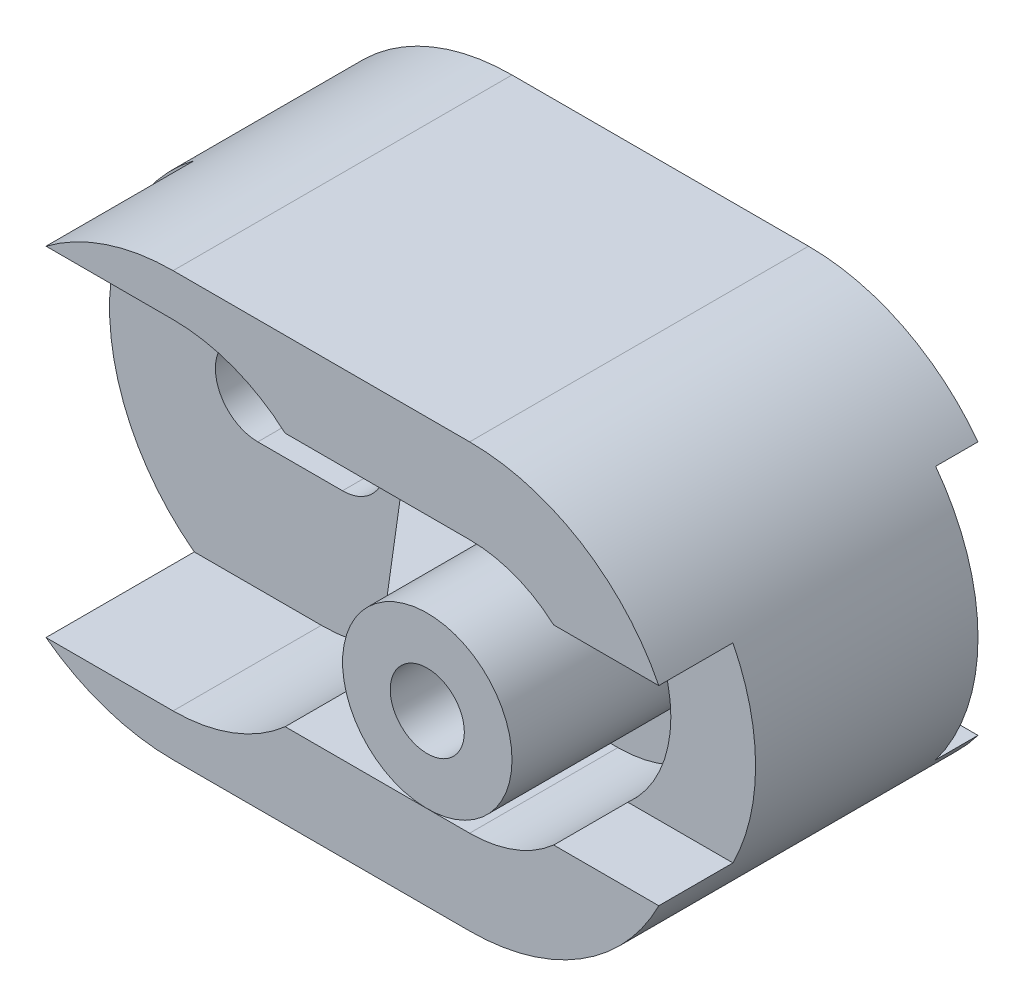
from build123d import *

# Parameters (mm, degrees)
BOSS_EXTRUDE1_DEPTH = 8
SKETCH2_W           = 1
SKETCH2_H           = 6
CUT_EXTRUDE1_DEPTH  = 9
CUT_EXTRUDE2_DEPTH  = 1
SKETCH4_R           = 2
CUT_EXTRUDE3_DEPTH  = 3.5
BOSS_EXTRUDE3_DEPTH = 0.5
CUT_EXTRUDE4_DEPTH  = 6.025665282
CUT_EXTRUDE5_DEPTH  = 1.75
SKETCH8_R           = 2
BOSS_EXTRUDE4_DEPTH = 1


with BuildPart() as part:
    # Sketch1 → Boss-Extrude1 (new body)
    with BuildSketch(Plane.XY):
        with BuildLine():
            Line((-3.5, 5), (3.5, 5))
            ThreePointArc((3.5, 5), (8.5, 0), (3.5, -5))
            Line((3.5, -5), (-3.5, -5))
            ThreePointArc((-3.5, -5), (-8.5, 0), (-3.5, 5))
        make_face()
    extrude(amount=BOSS_EXTRUDE1_DEPTH)

    # Sketch2 → Cut-Extrude1 (cut, symmetric)
    with BuildSketch(Plane(origin=(0, 0, 0), x_dir=(0, 0, -1), z_dir=(1, 0, 0))):
        with Locations((-0.5, 0)):
            Rectangle(SKETCH2_W, SKETCH2_H)
    extrude(amount=CUT_EXTRUDE1_DEPTH, both=True, mode=Mode.SUBTRACT)

    # Sketch3 → Cut-Extrude2 (cut)
    with BuildSketch(Plane(origin=(0, 0, 1), x_dir=(-1, 0, 0), z_dir=(0, 0, -1))):
        with BuildLine():
            Line((3.000904035, 2), (8.5, 2))
            ThreePointArc((8.5, 2), (10.5, 0), (8.5, -2))
            Line((8.5, -2), (3.000904035, -2))
            ThreePointArc((3.000904035, -2), (1.000904035, 0), (3.000904035, 2))
        make_face()
    extrude(amount=-CUT_EXTRUDE2_DEPTH, mode=Mode.SUBTRACT)

    # Sketch4 → Cut-Extrude3 (cut)
    with BuildSketch(Plane.XY.offset(8)):
        with BuildLine():
            Line((-9.161583496, 4), (-3.5, 4))
            ThreePointArc((-3.5, 4), (0.5, 0), (-3.5, -4))
            Line((-3.5, -4), (-9.161583496, -4))
            ThreePointArc((-9.161583496, -4), (-13.161583496, 0), (-9.161583496, 4))
        make_face()
        with BuildLine():
            Line((-3.5, 3), (3.5, 3))
            ThreePointArc((3.5, 3), (6.5, 0), (3.5, -3))
            Line((3.5, -3), (-3.5, -3))
            ThreePointArc((-3.5, -3), (-6.5, 0), (-3.5, 3))
        make_face()
        with Locations((3.5, 0)):
            Circle(SKETCH4_R, mode=Mode.SUBTRACT)
    extrude(amount=-CUT_EXTRUDE3_DEPTH, mode=Mode.SUBTRACT)

    # Sketch6 → Cut-Extrude4 (cut)
    with BuildSketch(Plane(origin=(0, 0, 2), x_dir=(-1, 0, 0), z_dir=(0, 0, -1))):
        with BuildLine():
            Line((3.000904035, 1), (5.000904035, 1))
            ThreePointArc((5.000904035, 1), (6.000904035, 0), (5.000904035, -1))
            Line((5.000904035, -1), (3.000904035, -1))
            ThreePointArc((3.000904035, -1), (2.000904035, 0), (3.000904035, 1))
        make_face()
    extrude(amount=-CUT_EXTRUDE4_DEPTH, mode=Mode.SUBTRACT)

    # Sketch7 → Cut-Extrude5 (cut)
    with BuildSketch(Plane.XY.offset(8)):
        with BuildLine():
            Line((7.965142775, 2.25), (5.484313483, 2.25))
            ThreePointArc((5.484313483, 2.25), (6.5, 0), (5.484313483, -2.25))
            Line((5.484313483, -2.25), (7.965142775, -2.25))
            ThreePointArc((7.965142775, -2.25), (8.5, 0), (7.965142775, 2.25))
        make_face()
    extrude(amount=-CUT_EXTRUDE5_DEPTH, mode=Mode.SUBTRACT)

    # Sketch8 → Boss-Extrude4 (add)
    with BuildSketch(Plane.XY.offset(8)):
        with Locations((3.5, 0)):
            Circle(SKETCH8_R)
    extrude(amount=BOSS_EXTRUDE4_DEPTH)

    # Sketch9 → M2.2x0.45 Tapped Hole1 (revolve, cut)
    with BuildSketch(Plane(origin=(3.5, 0, 9), x_dir=(0, -1, 0), z_dir=(1, 0, 0))):
        Polygon((0, 0), (0, 5.025753042), (0.875, 4.5), (0.875, 0), align=None)
    revolve(axis=Axis((3.5, 0, 15.35), (0, 0, -1)), mode=Mode.SUBTRACT)


with BuildPart() as body_2:
    # Sketch5 → Boss-Extrude3 (new body, symmetric)
    with BuildSketch(Plane(origin=(0, 0, 0), x_dir=(1, 0, 0), z_dir=(0, 1, 0))):
        Polygon((1.5, -8), (-1.5, -4.5), (1.5, -4.5), align=None)
    extrude(amount=BOSS_EXTRUDE3_DEPTH, both=True)


solid = Compound([part.part, body_2.part])
